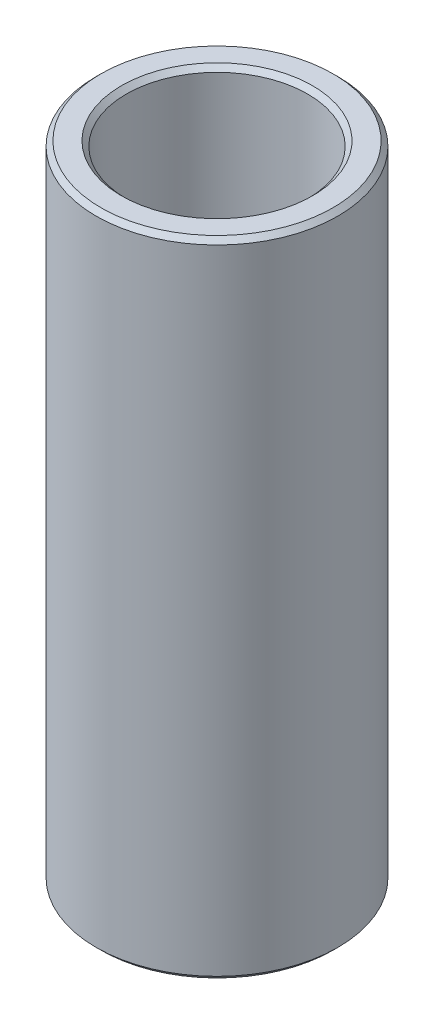
from build123d import *

# Parameters (mm, degrees)
SKETCH1_W     = 1.5875
SKETCH1_H     = 33.776182894
CHAMFER1_SIZE = 0.254


with BuildPart() as part:
    # Sketch1 → Revolve1 (revolve)
    with BuildSketch(Plane.XY):
        with Locations((5.55625, 87.531786411)):
            Rectangle(SKETCH1_W, SKETCH1_H)
    revolve(axis=Axis((0, 61.118694964, 0), (0, 1, 0)))

    # Chamfer1
    chamfer1_edges = [part.edges().sort_by_distance(p)[0] for p in [
        (-6.350000001, 70.643694964, 0),
        (-6.350000003, 104.419877858, 0),
        (-4.762500003, 104.419877858, 0),
        (-4.762500001, 70.643694964, 0),
    ]]
    chamfer(chamfer1_edges, length=CHAMFER1_SIZE)


solid = part.part
